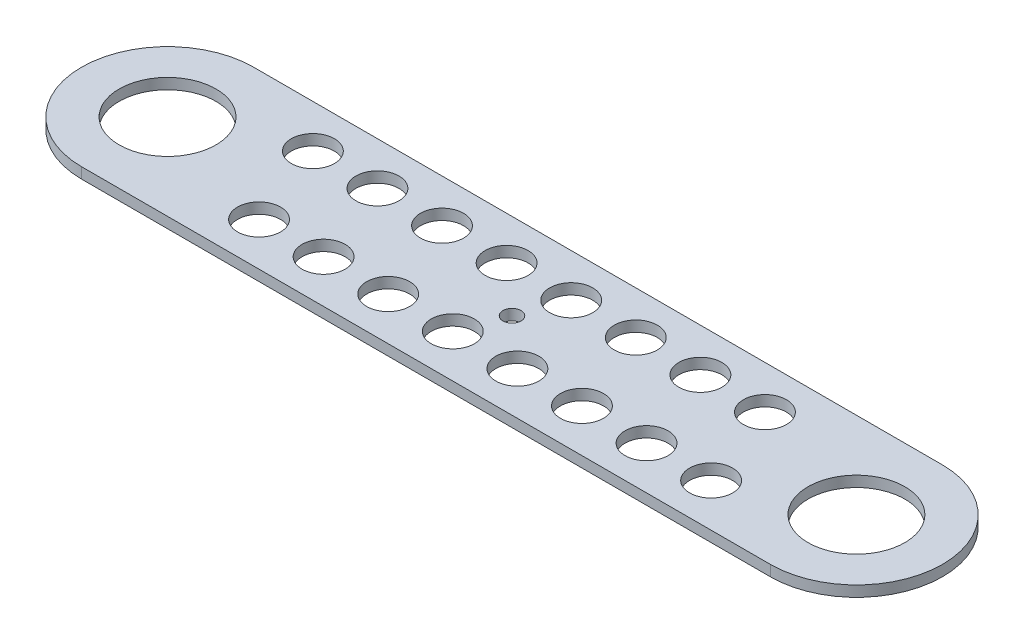
from build123d import *

# Parameters (mm, degrees)
SKETCH1_R           = 14.2875
BOSS_EXTRUDE1_DEPTH = 3.175
CUT_EXTRUDE1_REACH  = 5.175
SKETCH2_R           = 2.667
CUT_EXTRUDE2_REACH  = 5.175
SKETCH4_R           = 6.35


with BuildPart() as part:
    # Sketch1 → Boss-Extrude1 (new body)
    with BuildSketch(Plane(origin=(0, 0, 0), x_dir=(1, 0, 0), z_dir=(0, 1, 0))):
        with BuildLine():
            Line((0, 25.4), (203.2, 25.4))
            ThreePointArc((203.2, 25.4), (228.6, 0), (203.2, -25.4))
            Line((203.2, -25.4), (0, -25.4))
            ThreePointArc((0, -25.4), (-25.4, 0), (0, 25.4))
        make_face()
        Circle(SKETCH1_R, mode=Mode.SUBTRACT)
        with Locations((203.2, 0)):
            Circle(SKETCH1_R, mode=Mode.SUBTRACT)
    extrude(amount=BOSS_EXTRUDE1_DEPTH)

    # Sketch2 → Cut-Extrude1 (cut, up to next)
    with BuildSketch(Plane(origin=(0, 3.175, 0), x_dir=(1, 0, 0), z_dir=(0, 1, 0)), mode=Mode.PRIVATE) as cut_extrude1_sk1:
        with Locations((101.6, 0)):
            Circle(SKETCH2_R)
    cut_extrude1_tool1 = extrude(cut_extrude1_sk1.sketch, amount=-CUT_EXTRUDE1_REACH, mode=Mode.PRIVATE) & part.part
    add(cut_extrude1_tool1.solids().sort_by_distance((101.6, 3.175, 0))[0], mode=Mode.SUBTRACT)

    # Sketch4 → Cut-Extrude2 (cut, up to next)
    with BuildSketch(Plane.XZ, mode=Mode.PRIVATE) as cut_extrude2_sk1:
        with Locations((30.1625, -12.7)):
            Circle(SKETCH4_R)
    cut_extrude2_tool1 = extrude(cut_extrude2_sk1.sketch, amount=-CUT_EXTRUDE2_REACH, mode=Mode.PRIVATE) & part.part
    add(cut_extrude2_tool1.solids().sort_by_distance((30.1625, 0, -12.7))[0], mode=Mode.SUBTRACT)
    # Sketch4 → Cut-Extrude2 (cut, up to next)
    with BuildSketch(Plane.XZ, mode=Mode.PRIVATE) as cut_extrude2_sk2:
        with Locations((49.2125, -12.7)):
            Circle(SKETCH4_R)
    cut_extrude2_tool2 = extrude(cut_extrude2_sk2.sketch, amount=-CUT_EXTRUDE2_REACH, mode=Mode.PRIVATE) & part.part
    add(cut_extrude2_tool2.solids().sort_by_distance((49.2125, 0, -12.7))[0], mode=Mode.SUBTRACT)
    # Sketch4 → Cut-Extrude2 (cut, up to next)
    with BuildSketch(Plane.XZ, mode=Mode.PRIVATE) as cut_extrude2_sk3:
        with Locations((68.2625, -12.7)):
            Circle(SKETCH4_R)
    cut_extrude2_tool3 = extrude(cut_extrude2_sk3.sketch, amount=-CUT_EXTRUDE2_REACH, mode=Mode.PRIVATE) & part.part
    add(cut_extrude2_tool3.solids().sort_by_distance((68.2625, 0, -12.7))[0], mode=Mode.SUBTRACT)
    # Sketch4 → Cut-Extrude2 (cut, up to next)
    with BuildSketch(Plane.XZ, mode=Mode.PRIVATE) as cut_extrude2_sk4:
        with Locations((87.3125, -12.7)):
            Circle(SKETCH4_R)
    cut_extrude2_tool4 = extrude(cut_extrude2_sk4.sketch, amount=-CUT_EXTRUDE2_REACH, mode=Mode.PRIVATE) & part.part
    add(cut_extrude2_tool4.solids().sort_by_distance((87.3125, 0, -12.7))[0], mode=Mode.SUBTRACT)
    # Sketch4 → Cut-Extrude2 (cut, up to next)
    with BuildSketch(Plane.XZ, mode=Mode.PRIVATE) as cut_extrude2_sk5:
        with Locations((106.3625, -12.7)):
            Circle(SKETCH4_R)
    cut_extrude2_tool5 = extrude(cut_extrude2_sk5.sketch, amount=-CUT_EXTRUDE2_REACH, mode=Mode.PRIVATE) & part.part
    add(cut_extrude2_tool5.solids().sort_by_distance((106.3625, 0, -12.7))[0], mode=Mode.SUBTRACT)
    # Sketch4 → Cut-Extrude2 (cut, up to next)
    with BuildSketch(Plane.XZ, mode=Mode.PRIVATE) as cut_extrude2_sk6:
        with Locations((125.4125, -12.7)):
            Circle(SKETCH4_R)
    cut_extrude2_tool6 = extrude(cut_extrude2_sk6.sketch, amount=-CUT_EXTRUDE2_REACH, mode=Mode.PRIVATE) & part.part
    add(cut_extrude2_tool6.solids().sort_by_distance((125.4125, 0, -12.7))[0], mode=Mode.SUBTRACT)
    # Sketch4 → Cut-Extrude2 (cut, up to next)
    with BuildSketch(Plane.XZ, mode=Mode.PRIVATE) as cut_extrude2_sk7:
        with Locations((144.4625, -12.7)):
            Circle(SKETCH4_R)
    cut_extrude2_tool7 = extrude(cut_extrude2_sk7.sketch, amount=-CUT_EXTRUDE2_REACH, mode=Mode.PRIVATE) & part.part
    add(cut_extrude2_tool7.solids().sort_by_distance((144.4625, 0, -12.7))[0], mode=Mode.SUBTRACT)
    # Sketch4 → Cut-Extrude2 (cut, up to next)
    with BuildSketch(Plane.XZ, mode=Mode.PRIVATE) as cut_extrude2_sk8:
        with Locations((163.5125, -12.7)):
            Circle(SKETCH4_R)
    cut_extrude2_tool8 = extrude(cut_extrude2_sk8.sketch, amount=-CUT_EXTRUDE2_REACH, mode=Mode.PRIVATE) & part.part
    add(cut_extrude2_tool8.solids().sort_by_distance((163.5125, 0, -12.7))[0], mode=Mode.SUBTRACT)
    # Sketch4 → Cut-Extrude2 (cut, up to next)
    with BuildSketch(Plane.XZ, mode=Mode.PRIVATE) as cut_extrude2_sk9:
        with Locations((39.6875, 12.7)):
            Circle(SKETCH4_R)
    cut_extrude2_tool9 = extrude(cut_extrude2_sk9.sketch, amount=-CUT_EXTRUDE2_REACH, mode=Mode.PRIVATE) & part.part
    add(cut_extrude2_tool9.solids().sort_by_distance((39.6875, 0, 12.7))[0], mode=Mode.SUBTRACT)
    # Sketch4 → Cut-Extrude2 (cut, up to next)
    with BuildSketch(Plane.XZ, mode=Mode.PRIVATE) as cut_extrude2_sk10:
        with Locations((58.7375, 12.7)):
            Circle(SKETCH4_R)
    cut_extrude2_tool10 = extrude(cut_extrude2_sk10.sketch, amount=-CUT_EXTRUDE2_REACH, mode=Mode.PRIVATE) & part.part
    add(cut_extrude2_tool10.solids().sort_by_distance((58.7375, 0, 12.7))[0], mode=Mode.SUBTRACT)
    # Sketch4 → Cut-Extrude2 (cut, up to next)
    with BuildSketch(Plane.XZ, mode=Mode.PRIVATE) as cut_extrude2_sk11:
        with Locations((77.7875, 12.7)):
            Circle(SKETCH4_R)
    cut_extrude2_tool11 = extrude(cut_extrude2_sk11.sketch, amount=-CUT_EXTRUDE2_REACH, mode=Mode.PRIVATE) & part.part
    add(cut_extrude2_tool11.solids().sort_by_distance((77.7875, 0, 12.7))[0], mode=Mode.SUBTRACT)
    # Sketch4 → Cut-Extrude2 (cut, up to next)
    with BuildSketch(Plane.XZ, mode=Mode.PRIVATE) as cut_extrude2_sk12:
        with Locations((96.8375, 12.7)):
            Circle(SKETCH4_R)
    cut_extrude2_tool12 = extrude(cut_extrude2_sk12.sketch, amount=-CUT_EXTRUDE2_REACH, mode=Mode.PRIVATE) & part.part
    add(cut_extrude2_tool12.solids().sort_by_distance((96.8375, 0, 12.7))[0], mode=Mode.SUBTRACT)
    # Sketch4 → Cut-Extrude2 (cut, up to next)
    with BuildSketch(Plane.XZ, mode=Mode.PRIVATE) as cut_extrude2_sk13:
        with Locations((115.8875, 12.7)):
            Circle(SKETCH4_R)
    cut_extrude2_tool13 = extrude(cut_extrude2_sk13.sketch, amount=-CUT_EXTRUDE2_REACH, mode=Mode.PRIVATE) & part.part
    add(cut_extrude2_tool13.solids().sort_by_distance((115.8875, 0, 12.7))[0], mode=Mode.SUBTRACT)
    # Sketch4 → Cut-Extrude2 (cut, up to next)
    with BuildSketch(Plane.XZ, mode=Mode.PRIVATE) as cut_extrude2_sk14:
        with Locations((134.9375, 12.7)):
            Circle(SKETCH4_R)
    cut_extrude2_tool14 = extrude(cut_extrude2_sk14.sketch, amount=-CUT_EXTRUDE2_REACH, mode=Mode.PRIVATE) & part.part
    add(cut_extrude2_tool14.solids().sort_by_distance((134.9375, 0, 12.7))[0], mode=Mode.SUBTRACT)
    # Sketch4 → Cut-Extrude2 (cut, up to next)
    with BuildSketch(Plane.XZ, mode=Mode.PRIVATE) as cut_extrude2_sk15:
        with Locations((153.9875, 12.7)):
            Circle(SKETCH4_R)
    cut_extrude2_tool15 = extrude(cut_extrude2_sk15.sketch, amount=-CUT_EXTRUDE2_REACH, mode=Mode.PRIVATE) & part.part
    add(cut_extrude2_tool15.solids().sort_by_distance((153.9875, 0, 12.7))[0], mode=Mode.SUBTRACT)
    # Sketch4 → Cut-Extrude2 (cut, up to next)
    with BuildSketch(Plane.XZ, mode=Mode.PRIVATE) as cut_extrude2_sk16:
        with Locations((173.0375, 12.7)):
            Circle(SKETCH4_R)
    cut_extrude2_tool16 = extrude(cut_extrude2_sk16.sketch, amount=-CUT_EXTRUDE2_REACH, mode=Mode.PRIVATE) & part.part
    add(cut_extrude2_tool16.solids().sort_by_distance((173.0375, 0, 12.7))[0], mode=Mode.SUBTRACT)


solid = part.part
